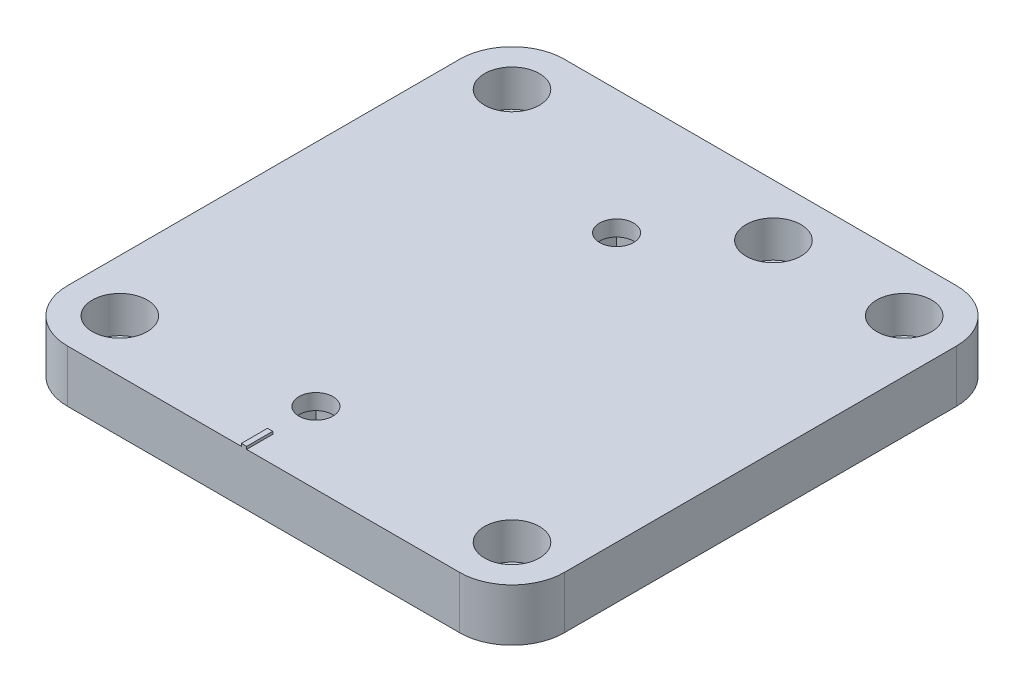
from build123d import *

# Parameters (mm, degrees)
SKETCH_1_W          = 95
SKETCH_1_H          = 95
SKETCH_1_R          = 3.2
EXTRUDE_1_DEPTH     = 10
SKETCH_2_R          = 5.25
CUT_EXTRUDE_1_DEPTH = 7
FILLET_1_R          = 10
SKETCH_3_R          = 3.25
CUT_EXTRUDE_2_DEPTH = 10
SKETCH_4_W          = 10.4
SKETCH_4_H          = 10.4
SKETCH_4_R          = 3.25
CUT_EXTRUDE_3_DEPTH = 7
SKETCH_5_W          = 1
SKETCH_5_H          = 5
EXTRUDE_2_DEPTH     = 0.5


with BuildPart() as part:
    # 스케치1 → 보스-돌출1 (new body)
    with BuildSketch(Plane(origin=(0, 0, 0), x_dir=(1, 0, 0), z_dir=(0, 1, 0))):
        with Locations((3.75, -46.25)):
            Rectangle(SKETCH_1_W, SKETCH_1_H)
        with Locations((16.25, -8.75)):
            Circle(SKETCH_1_R, mode=Mode.SUBTRACT)
        with Locations((-33.75, -8.75)):
            Circle(SKETCH_1_R, mode=Mode.SUBTRACT)
        with Locations((41.25, -8.75)):
            Circle(SKETCH_1_R, mode=Mode.SUBTRACT)
        with Locations((-33.75, -83.75)):
            Circle(SKETCH_1_R, mode=Mode.SUBTRACT)
        with Locations((41.25, -83.75)):
            Circle(SKETCH_1_R, mode=Mode.SUBTRACT)
    extrude(amount=EXTRUDE_1_DEPTH)

    # 스케치2 → 컷-돌출1 (cut)
    with BuildSketch(Plane(origin=(0, 10, 0), x_dir=(1, 0, 0), z_dir=(0, 1, 0))):
        with Locations((16.25, -8.75)):
            Circle(SKETCH_2_R)
        with Locations((-33.75, -8.75)):
            Circle(SKETCH_2_R)
        with Locations((41.25, -8.75)):
            Circle(SKETCH_2_R)
        with Locations((41.25, -83.75)):
            Circle(SKETCH_2_R)
        with Locations((-33.75, -83.75)):
            Circle(SKETCH_2_R)
    extrude(amount=-CUT_EXTRUDE_1_DEPTH, mode=Mode.SUBTRACT)

    # 필렛1
    fillet_1_edges = [part.edges().sort_by_distance(p)[0] for p in [
        (51.25, 5, -1.25),
        (51.25, 5, 93.75),
        (-43.75, 5, 93.75),
        (-43.75, 5, -1.25),
    ]]
    fillet(fillet_1_edges, radius=FILLET_1_R)

    # 스케치3 → 컷-돌출2 (cut)
    with BuildSketch(Plane(origin=(0, 10, 0), x_dir=(1, 0, 0), z_dir=(0, 1, 0))):
        with Locations((0, -22.5)):
            Circle(SKETCH_3_R)
        with Locations((0, -80)):
            Circle(SKETCH_3_R)
    extrude(amount=-CUT_EXTRUDE_2_DEPTH, mode=Mode.SUBTRACT)

    # 스케치4 → 컷-돌출3 (cut)
    with BuildSketch(Plane.XZ):
        with Locations((0, 22.5)):
            Rectangle(SKETCH_4_W, SKETCH_4_H)
        with Locations((0, 22.5)):
            Circle(SKETCH_4_R, mode=Mode.SUBTRACT)
        with Locations((0, 80)):
            Rectangle(SKETCH_4_W, SKETCH_4_H)
        with Locations((0, 80)):
            Circle(SKETCH_4_R, mode=Mode.SUBTRACT)
    extrude(amount=-CUT_EXTRUDE_3_DEPTH, mode=Mode.SUBTRACT)

    # 스케치5 → 보스-돌출2 (add)
    with BuildSketch(Plane(origin=(0, 10, 0), x_dir=(1, 0, 0), z_dir=(0, 1, 0))):
        with Locations((0, -91.25)):
            Rectangle(SKETCH_5_W, SKETCH_5_H)
    extrude(amount=EXTRUDE_2_DEPTH)


solid = part.part
